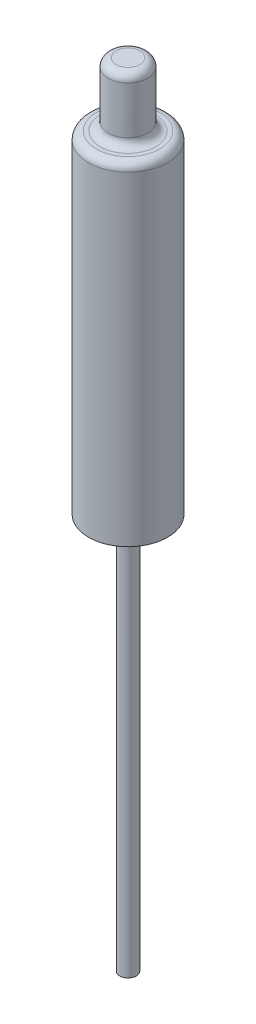
from build123d import *

# Parameters (mm, degrees)
ESQUISSE2_R        = 1.05
BOSS_EXTRU_1_DEPTH = 100
ESQUISSE3_R        = 2.5
BOSS_EXTRU_2_DEPTH = 8
ESQUISSE4_R        = 5
BOSS_EXTRU_3_DEPTH = 42
CONG_4_R           = 1
CONG_5_R           = 1
CONG_6_R           = 1


with BuildPart() as part:
    # Esquisse2 → Boss.-Extru.1 (new body)
    with BuildSketch(Plane(origin=(0, 0, 0), x_dir=(1, 0, 0), z_dir=(0, 1, 0))):
        Circle(ESQUISSE2_R)
    extrude(amount=BOSS_EXTRU_1_DEPTH)

    # Esquisse3 → Boss.-Extru.2 (add)
    with BuildSketch(Plane(origin=(0, 100, 0), x_dir=(1, 0, 0), z_dir=(0, 1, 0))):
        Circle(ESQUISSE3_R)
    extrude(amount=-BOSS_EXTRU_2_DEPTH)

    # Esquisse4 → Boss.-Extru.3 (add)
    with BuildSketch(Plane.XZ.offset(-92)):
        Circle(ESQUISSE4_R)
    extrude(amount=BOSS_EXTRU_3_DEPTH)

    # Congé4
    cong_4_edges = [part.edges().sort_by_distance(p)[0] for p in [
        (-2.5, 100, 0),
    ]]
    fillet(cong_4_edges, radius=CONG_4_R)

    # Congé5
    cong_5_edges = [part.edges().sort_by_distance(p)[0] for p in [
        (-5, 92, 0),
    ]]
    fillet(cong_5_edges, radius=CONG_5_R)

    # Congé6
    cong_6_edges = [part.edges().sort_by_distance(p)[0] for p in [
        (-2.5, 92, 0),
    ]]
    fillet(cong_6_edges, radius=CONG_6_R)


solid = part.part
